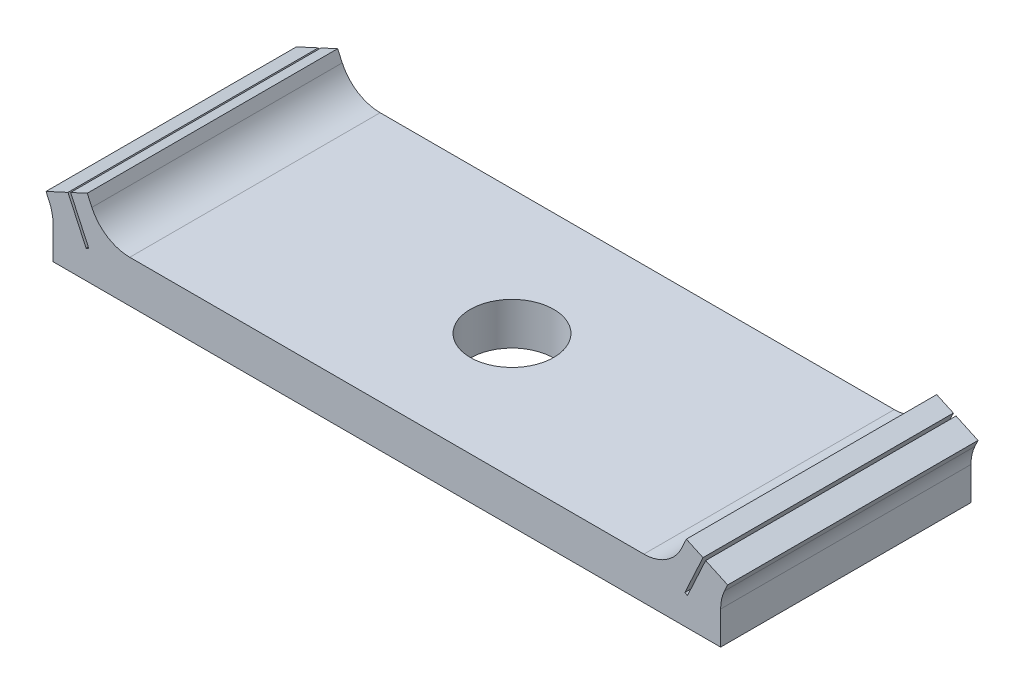
from build123d import *

# Parameters (mm, degrees)
BOSS_EXTRUDE1_DEPTH = 30
FILLET1_R           = 5
SKETCH2_R           = 5
CUT_EXTRUDE1_DEPTH  = 10


with BuildPart() as part:
    # Sketch1 → Boss-Extrude1 (new body)
    with BuildSketch(Plane.XY):
        Polygon((40, -2.528830443), (40, 2.528830443), (36.805899489, 2.528830443), (36.02578828, 0.838966186), (35.708014936, 0.9856635), (36.4204046, 2.528830443), (34, 2.528830443), (-34, 2.528830443), (-36.4204046, 2.528830443), (-35.708014936, 0.9856635), (-36.02578828, 0.838966186), (-36.805899489, 2.528830443), (-40, 2.528830443), (-40, -2.528830443), align=None)
        Polygon((-40.838270366, 4.344678122), (-40, 2.528830443), (-36.805899489, 2.528830443), (-38.205291231, 5.560170152), align=None)
        Polygon((-36.4204046, 2.528830443), (-34, 2.528830443), (-35.892316174, 6.627935069), (-37.887517887, 5.706867466), align=None)
        Polygon((34, 2.528830443), (36.4204046, 2.528830443), (37.887517887, 5.706867466), (35.892316174, 6.627935069), align=None)
        Polygon((36.805899489, 2.528830443), (40, 2.528830443), (40.838270366, 4.344678122), (38.205291231, 5.560170152), align=None)
    extrude(amount=BOSS_EXTRUDE1_DEPTH)

    # Fillet1
    fillet1_edges = [part.edges().sort_by_distance(p)[0] for p in [
        (34, 2.528830443, 15),
        (40, 2.528830443, 15),
        (-40, 2.528830443, 15),
        (-34, 2.528830443, 15),
    ]]
    fillet(fillet1_edges, radius=FILLET1_R)

    # Sketch2 → Cut-Extrude1 (cut)
    with BuildSketch(Plane(origin=(0, 2.528830443, 0), x_dir=(1, 0, 0), z_dir=(0, 1, 0))):
        with Locations((0, -15)):
            Circle(SKETCH2_R)
    extrude(amount=-CUT_EXTRUDE1_DEPTH, mode=Mode.SUBTRACT)


solid = part.part
